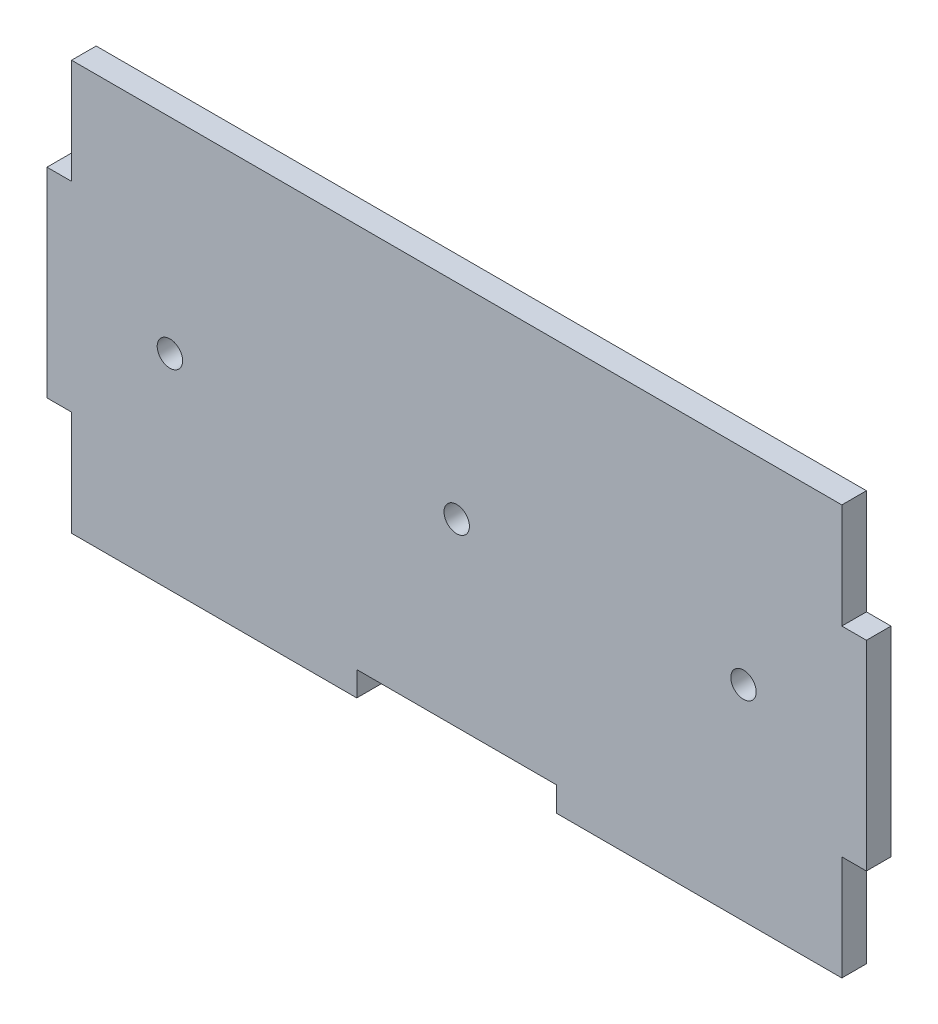
from build123d import *

# Parameters (mm, degrees)
SALIENTE_EXTRUIR1_DEPTH = 3
CROQUIS1_R              = 1.55
CORTAR_EXTRUIR1_DEPTH   = 10


with BuildPart() as part:
    # Model → Saliente-Extruir1 (new body)
    with BuildSketch(Plane.XY):
        Polygon((186, 103), (186, 90.195), (183, 90.195), (183, 65.805), (186, 65.805), (186, 53), (220.805, 53), (220.805, 56), (245.195, 56), (245.195, 53), (269.585, 53), (280, 53), (280, 65.805), (283, 65.805), (283, 90.195), (280, 90.195), (280, 103), align=None)
    extrude(amount=SALIENTE_EXTRUIR1_DEPTH)

    # Croquis1 → Cortar-Extruir1 (cut)
    with BuildSketch(Plane.XY.offset(3)):
        with Locations((233, 78)):
            Circle(CROQUIS1_R)
        with Locations((198, 78)):
            Circle(CROQUIS1_R)
        with Locations((268, 78)):
            Circle(CROQUIS1_R)
    extrude(amount=-CORTAR_EXTRUIR1_DEPTH, mode=Mode.SUBTRACT)


solid = part.part
